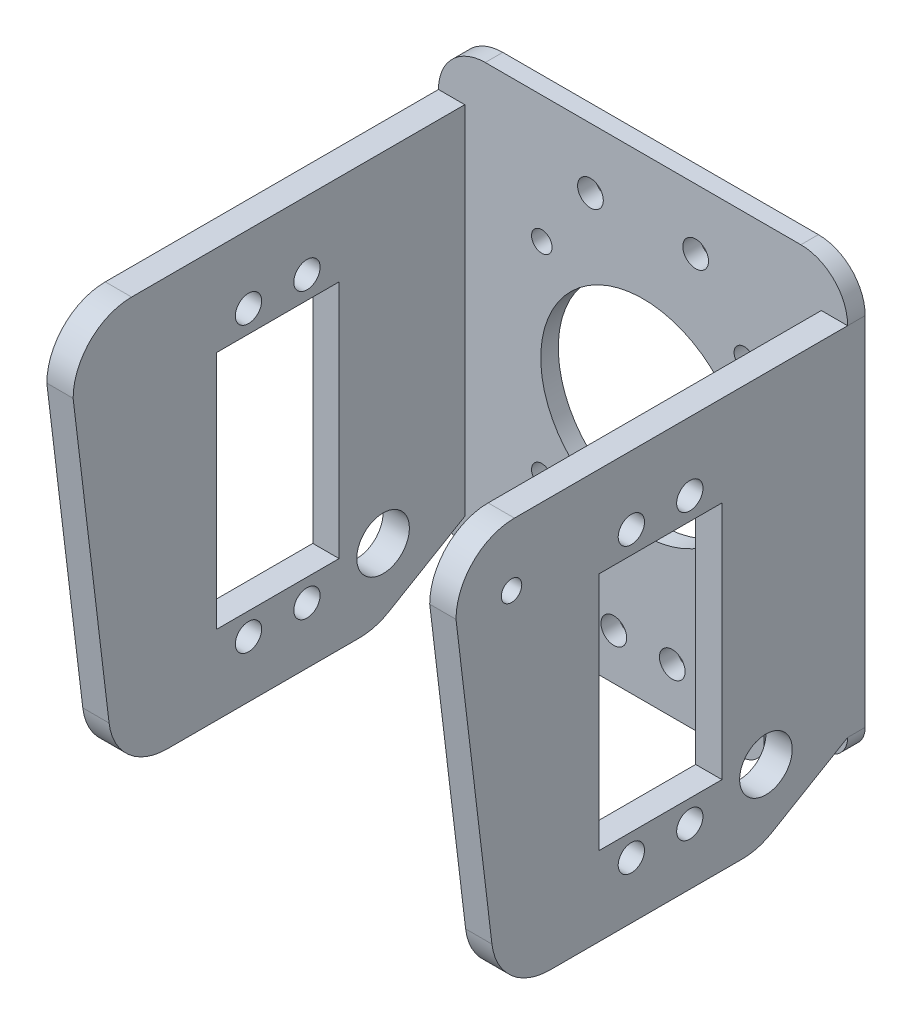
from build123d import *

# Parameters (mm, degrees)
SKETCH_2_R          = 17.5
SKETCH_2_R_2        = 1.75
EXTRUDE_2_DEPTH     = 3
SKETCH_4_W          = 4.5
SKETCH_4_H          = 70
EXTRUDE_3_DEPTH     = 67
CUT_EXTRUDE_4_DEPTH = 71
SKETCH_6_R          = 2.25
SKETCH_6_W          = 21
SKETCH_6_H          = 41
CUT_EXTRUDE_6_DEPTH = 71
CUT_EXTRUDE_7_REACH = 72
SKETCH_7_R          = 1.75
SKETCH_8_R          = 4.5
CUT_EXTRUDE_8_DEPTH = 71
SKETCH_9_R          = 2.2
CUT_EXTRUDE_9_DEPTH = 4


with BuildPart() as part:
    # 草图2 → 凸台-拉伸2 (new body)
    with BuildSketch(Plane.XY):
        with BuildLine():
            Line((-31, -34), (-20.725119278, -34))
            Line((-20.725119278, -34), (-20.725119278, -38))
            ThreePointArc((-20.725119278, -38), (-19.553546403, -40.828427125), (-16.725119278, -42))
            Line((-16.725119278, -42), (16.725119278, -42))
            ThreePointArc((16.725119278, -42), (19.553546403, -40.828427125), (20.725119278, -38))
            Line((20.725119278, -38), (20.725119278, -34))
            Line((20.725119278, -34), (31, -34))
            ThreePointArc((31, -34), (33.828427125, -32.828427125), (35, -30))
            Line((35, -30), (35, 31))
            ThreePointArc((35, 31), (32.656854249, 36.656854249), (27, 39))
            Line((27, 39), (-27, 39))
            ThreePointArc((-27, 39), (-32.656854249, 36.656854249), (-35, 31))
            Line((-35, 31), (-35, -30))
            ThreePointArc((-35, -30), (-33.828427125, -32.828427125), (-31, -34))
        make_face()
        Circle(SKETCH_2_R, mode=Mode.SUBTRACT)
        with Locations((-17.324116139, 17.324116139)):
            Circle(SKETCH_2_R_2, mode=Mode.SUBTRACT)
        with Locations((17.324116139, 17.324116139)):
            Circle(SKETCH_2_R_2, mode=Mode.SUBTRACT)
        with Locations((17.324116139, -17.324116139)):
            Circle(SKETCH_2_R_2, mode=Mode.SUBTRACT)
        with Locations((-17.324116139, -17.324116139)):
            Circle(SKETCH_2_R_2, mode=Mode.SUBTRACT)
    extrude(amount=EXTRUDE_2_DEPTH)

    # 草图4 → 凸台-拉伸3 (add)
    with BuildSketch(Plane.XY.offset(3)):
        with Locations((32.75, -4)):
            Rectangle(SKETCH_4_W, SKETCH_4_H)
    extrude_3 = extrude(amount=EXTRUDE_3_DEPTH)

    # 草图5 → 切除-拉伸4 (cut, through all)
    with BuildSketch(Plane(origin=(35, 0, 0), x_dir=(0, 0, -1), z_dir=(1, 0, 0))):
        with BuildLine():
            ThreePointArc((-70, 21), (-67.071067812, 28.071067812), (-60, 31))
            Line((-60, 31), (-70, 31))
            Line((-70, 31), (-70, 21))
        make_face()
        with BuildLine():
            Line((-63.851082976, -30.192562933), (-70, 21))
            Line((-70, 21), (-70, -39))
            Line((-70, -39), (-53.922447942, -39))
            ThreePointArc((-53.922447942, -39), (-60.558499881, -36.480829811), (-63.851082976, -30.192562933))
        make_face()
        with BuildLine():
            Line((-3, -39), (-3, -30))
            Line((-3, -30), (-15.989445023, -37.624176182))
            ThreePointArc((-15.989445023, -37.624176182), (-18.428611976, -38.649916109), (-21.051419458, -39))
            Line((-21.051419458, -39), (-3, -39))
        make_face()
    cut_extrude_4 = extrude(amount=-CUT_EXTRUDE_4_DEPTH, mode=Mode.SUBTRACT)

    # 镜向2: 凸台-拉伸3, 切除-拉伸4 across plane
    add(extrude_3.mirror(Plane(origin=(0, 0, 0), x_dir=(0, 0, 1), z_dir=(1, 0, 0))))
    add(cut_extrude_4.mirror(Plane(origin=(0, 0, 0), x_dir=(0, 0, 1), z_dir=(1, 0, 0))), mode=Mode.SUBTRACT)

    # 草图6 → 切除-拉伸6 (cut, through all)
    with BuildSketch(Plane(origin=(35, 0, 0), x_dir=(0, 0, -1), z_dir=(1, 0, 0))):
        with Locations((-40, -29.315)):
            Circle(SKETCH_6_R)
        with Locations((-30, -29.315)):
            Circle(SKETCH_6_R)
        with Locations((-35, -5)):
            Rectangle(SKETCH_6_W, SKETCH_6_H)
        with Locations((-40, 19.315)):
            Circle(SKETCH_6_R)
        with Locations((-30, 19.315)):
            Circle(SKETCH_6_R)
    extrude(amount=-CUT_EXTRUDE_6_DEPTH, mode=Mode.SUBTRACT)

    # 草图7 → 切除-拉伸7 (cut, up to next)
    with BuildSketch(Plane(origin=(35, 0, 0), x_dir=(0, 0, -1), z_dir=(1, 0, 0)), mode=Mode.PRIVATE) as cut_extrude_7_sk1:
        with Locations((-60.5, 20.5)):
            Circle(SKETCH_7_R)
    cut_extrude_7_tool1 = extrude(cut_extrude_7_sk1.sketch, amount=-CUT_EXTRUDE_7_REACH, mode=Mode.PRIVATE) & part.part
    add(cut_extrude_7_tool1.solids().sort_by_distance((35, 20.5, 60.5))[0], mode=Mode.SUBTRACT)

    # 草图8 → 切除-拉伸8 (cut, through all)
    with BuildSketch(Plane(origin=(35, 0, 0), x_dir=(0, 0, -1), z_dir=(1, 0, 0))):
        with Locations((-16.97928935, -27)):
            Circle(SKETCH_8_R)
    extrude(amount=-CUT_EXTRUDE_8_DEPTH, mode=Mode.SUBTRACT)

    # 草图9 → 切除-拉伸9 (cut, through all)
    with BuildSketch(Plane.XY.offset(3)):
        with Locations((9, 28.65)):
            Circle(SKETCH_9_R)
        with Locations((-9, 28.65)):
            Circle(SKETCH_9_R)
        with Locations((5, -34.165)):
            Circle(SKETCH_9_R)
        with Locations((-5, -34.165)):
            Circle(SKETCH_9_R)
    extrude(amount=-CUT_EXTRUDE_9_DEPTH, mode=Mode.SUBTRACT)


solid = part.part
